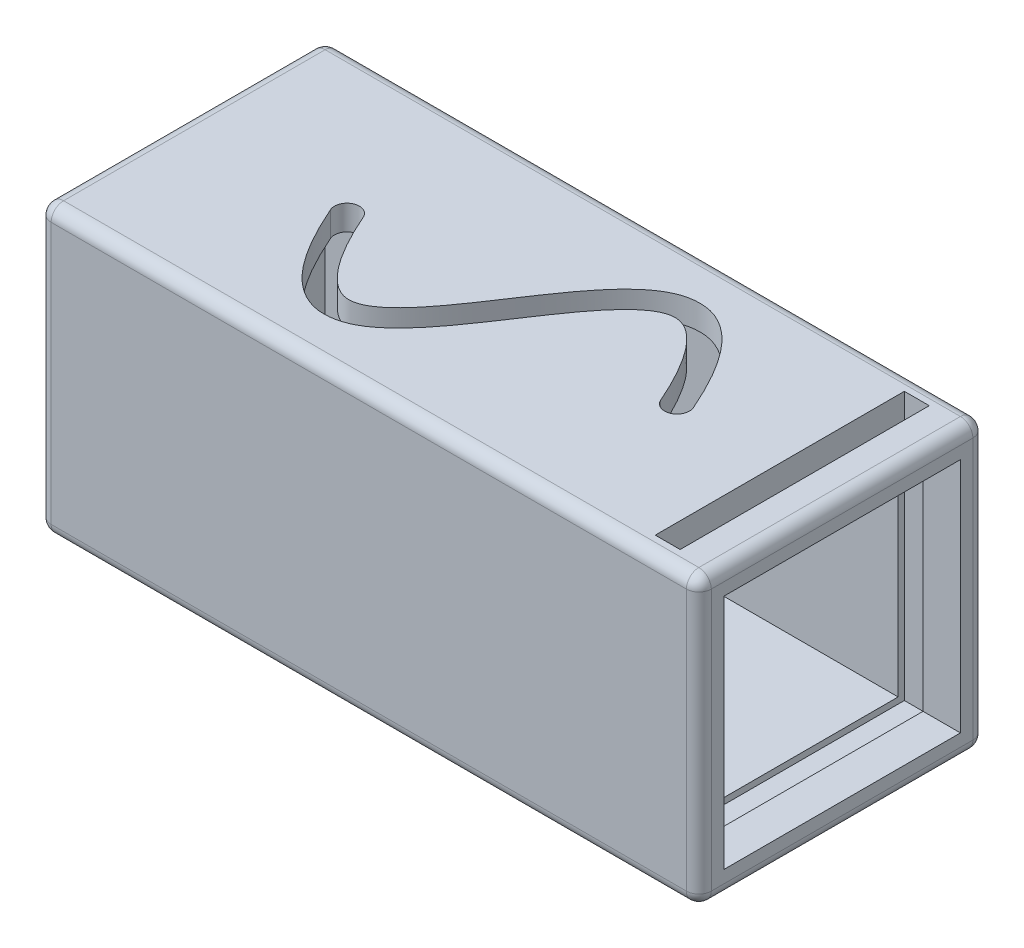
from build123d import *

# Parameters (mm, degrees)
SKETCH1_W           = 53
SKETCH1_H           = 23
BOSS_EXTRUDE1_DEPTH = 2
SKETCH3_W           = 53
SKETCH3_H           = 23
SKETCH3_W_2         = 49
SKETCH3_H_2         = 19
BOSS_EXTRUDE2_DEPTH = 19
SKETCH5_W           = 53
SKETCH5_H           = 23
BOSS_EXTRUDE3_DEPTH = 2
CUT_EXTRUDE1_REACH  = 25
CUT_EXTRUDE2_REACH  = 55
CUT_EXTRUDE3_REACH  = 55
SKETCH9_W           = 19
SKETCH9_H           = 19
SKETCH10_W          = 2
SKETCH10_H          = 20
CUT_EXTRUDE4_DEPTH  = 21.5
FILLET1_R           = 1


with BuildPart() as part:
    # Sketch1 → Boss-Extrude1 (new body)
    with BuildSketch(Plane(origin=(0, 0, 0), x_dir=(1, 0, 0), z_dir=(0, 1, 0))):
        with Locations((26.5, 11.5)):
            Rectangle(SKETCH1_W, SKETCH1_H)
        with BuildLine():
            ThreePointArc((14.167979799, 11.103372859), (12.853372859, 10.582020201), (12.332020201, 11.896627141))
            add(Edge.make_bspline(
                [(12.332020201, 11.896627141), (12.469480865, 12.214775093), (12.762832878, 12.862826424), (13.335933972, 14.00565416), (14.069559606, 15.249143301), (14.976946321, 16.440651864), (16.244519266, 17.664776994), (18.013213928, 18.520696074), (20.198395592, 18.347411342), (22.11067197, 17.353298864), (24.473450461, 15.381830316), (26.713246554, 12.781426707), (28.903370071, 10.24854759), (30.508326384, 8.567330823), (32.048368225, 7.290846303), (33.447040029, 6.607713215), (34.391956609, 6.552903154), (35.163585916, 6.806063587), (35.804481551, 7.206405018), (36.50793545, 7.876095679), (37.256247569, 8.85306811), (37.906431149, 9.951709918), (38.429850366, 10.994805159), (38.704188556, 11.600765219), (38.832020201, 11.896627141)],
                knots=[0, 0, 0, 0, 0.015625, 0.03125, 0.0625, 0.09375, 0.125, 0.1875, 0.25, 0.3125, 0.375, 0.5, 0.5625, 0.625, 0.6875, 0.75, 0.8125, 0.84375, 0.875, 0.90625, 0.9375, 0.96875, 0.984375, 1, 1, 1, 1], degree=3))
            ThreePointArc((38.832020201, 11.896627141), (40.146627141, 12.417979799), (40.667979799, 11.103372859))
            add(Edge.make_bspline(
                [(14.167979799, 11.103372859), (14.295811444, 11.399234781), (14.570149634, 12.005194841), (15.093568851, 13.048290082), (15.743752431, 14.14693189), (16.49206455, 15.123904321), (17.195518449, 15.793594982), (17.836414084, 16.193936413), (18.608043391, 16.447096846), (19.552959971, 16.392286785), (20.951631775, 15.709153697), (22.491673616, 14.432669177), (24.096629929, 12.75145241), (26.286753446, 10.218573293), (28.526549539, 7.618169684), (30.88932803, 5.646701136), (32.801604408, 4.652588658), (34.986786072, 4.479303926), (36.755480734, 5.335223006), (38.023053679, 6.559348136), (38.930440394, 7.750856699), (39.664066028, 8.99434584), (40.237167122, 10.137173576), (40.530519135, 10.785224907), (40.667979799, 11.103372859)],
                knots=[0, 0, 0, 0, 0.015625, 0.03125, 0.0625, 0.09375, 0.125, 0.15625, 0.1875, 0.25, 0.3125, 0.375, 0.4375, 0.5, 0.625, 0.6875, 0.75, 0.8125, 0.875, 0.90625, 0.9375, 0.96875, 0.984375, 1, 1, 1, 1], degree=3))
        make_face(mode=Mode.SUBTRACT)
    extrude(amount=BOSS_EXTRUDE1_DEPTH)

    # Sketch3 → Boss-Extrude2 (add)
    with BuildSketch(Plane(origin=(0, 2, 0), x_dir=(1, 0, 0), z_dir=(0, 1, 0))):
        with Locations((26.5, 11.5)):
            Rectangle(SKETCH3_W, SKETCH3_H)
        with Locations((26.5, 11.5)):
            Rectangle(SKETCH3_W_2, SKETCH3_H_2, mode=Mode.SUBTRACT)
    extrude(amount=BOSS_EXTRUDE2_DEPTH)

    # Sketch5 → Boss-Extrude3 (add)
    with BuildSketch(Plane(origin=(0, 21, 0), x_dir=(1, 0, 0), z_dir=(0, 1, 0))):
        with Locations((26.5, 11.5)):
            Rectangle(SKETCH5_W, SKETCH5_H)
    extrude(amount=BOSS_EXTRUDE3_DEPTH)

    # Sketch7 → Cut-Extrude1 (cut, up to next)
    with BuildSketch(Plane(origin=(0, 23, 0), x_dir=(1, 0, 0), z_dir=(0, 1, 0)), mode=Mode.PRIVATE) as cut_extrude1_sk1:
        with BuildLine():
            ThreePointArc((12.334246428, 11.098259542), (12.848259542, 12.415753572), (14.165753572, 11.901740458))
            add(Edge.make_bspline(
                [(14.165753572, 11.901740458), (14.319569541, 11.551122241), (14.647608492, 10.832183671), (15.265371347, 9.591848537), (16.019360121, 8.279562849), (16.869534053, 7.103102818), (17.654222781, 6.289831839), (18.34890312, 5.806641268), (18.938193167, 5.587801008), (19.463132193, 5.549931301), (20.195435511, 5.70020599), (21.280226269, 6.347578401), (22.712802701, 7.841295003), (24.17836504, 9.816346352), (26.159265484, 12.791351284), (28.18067633, 15.841945555), (30.383820425, 18.160165201), (32.247719208, 19.361531089), (34.538967294, 19.56728313), (36.355209033, 18.558624621), (37.689381474, 17.159152284), (38.675063468, 15.789280734), (39.49940357, 14.351448085), (40.159389491, 13.025812725), (40.503651701, 12.271246104), (40.665753572, 11.901740458)],
                knots=[0, 0, 0, 0, 0.015625, 0.03125, 0.0625, 0.09375, 0.125, 0.15625, 0.1875, 0.21875, 0.25, 0.3125, 0.375, 0.4375, 0.5, 0.625, 0.6875, 0.75, 0.8125, 0.875, 0.90625, 0.9375, 0.96875, 0.984375, 1, 1, 1, 1], degree=3))
            ThreePointArc((40.665753572, 11.901740458), (40.151740458, 10.584246428), (38.834246428, 11.098259542))
            add(Edge.make_bspline(
                [(12.334246428, 11.098259542), (12.496348299, 10.728753896), (12.840610509, 9.974187275), (13.50059643, 8.648551915), (14.324936532, 7.210719266), (15.310618526, 5.840847716), (16.644790967, 4.441375379), (18.461032706, 3.43271687), (20.752280792, 3.638468911), (22.616179575, 4.839834799), (24.81932367, 7.158054445), (26.840734516, 10.208648716), (28.82163496, 13.183653648), (30.287197299, 15.158704997), (31.719773731, 16.652421599), (32.804564489, 17.29979401), (33.536867807, 17.450068699), (34.061806833, 17.412198992), (34.65109688, 17.193358732), (35.345777219, 16.710168161), (36.130465947, 15.896897182), (36.980639879, 14.720437151), (37.734628653, 13.408151463), (38.352391508, 12.167816329), (38.680430459, 11.448877759), (38.834246428, 11.098259542)],
                knots=[0, 0, 0, 0, 0.015625, 0.03125, 0.0625, 0.09375, 0.125, 0.1875, 0.25, 0.3125, 0.375, 0.5, 0.5625, 0.625, 0.6875, 0.75, 0.78125, 0.8125, 0.84375, 0.875, 0.90625, 0.9375, 0.96875, 0.984375, 1, 1, 1, 1], degree=3))
        make_face()
    cut_extrude1_tool1 = extrude(cut_extrude1_sk1.sketch, amount=-CUT_EXTRUDE1_REACH, mode=Mode.PRIVATE) & part.part
    add(cut_extrude1_tool1.solids().sort_by_distance((26.5, 23, -11.500446))[0], mode=Mode.SUBTRACT)

    # Sketch8 → Cut-Extrude2 (cut, up to next)
    with BuildSketch(Plane.ZY, mode=Mode.PRIVATE) as cut_extrude2_sk1:
        Polygon((-4, 8), (-4, 15), (-5.4, 15), (-7.1, 15.5), (-8.5, 15.5), (-8.5, 7.5), (-7.1, 7.5), (-5.4, 8), align=None)
    cut_extrude2_tool1 = extrude(cut_extrude2_sk1.sketch, amount=-CUT_EXTRUDE2_REACH, mode=Mode.PRIVATE) & part.part
    add(cut_extrude2_tool1.solids().sort_by_distance((0, 11.5, -6.321432))[0], mode=Mode.SUBTRACT)

    # Sketch9 → Cut-Extrude3 (cut, up to next)
    with BuildSketch(Plane(origin=(53, 0, 0), x_dir=(0, 0, -1), z_dir=(1, 0, 0)), mode=Mode.PRIVATE) as cut_extrude3_sk1:
        with Locations((11.5, 11.5)):
            Rectangle(SKETCH9_W, SKETCH9_H)
    cut_extrude3_tool1 = extrude(cut_extrude3_sk1.sketch, amount=-CUT_EXTRUDE3_REACH, mode=Mode.PRIVATE) & part.part
    add(cut_extrude3_tool1.solids().sort_by_distance((53, 11.5, -11.5))[0], mode=Mode.SUBTRACT)

    # Sketch10 → Cut-Extrude4 (cut)
    with BuildSketch(Plane(origin=(0, 23, 0), x_dir=(1, 0, 0), z_dir=(0, 1, 0))):
        with Locations((49, 11.5)):
            Rectangle(SKETCH10_W, SKETCH10_H)
    extrude(amount=-CUT_EXTRUDE4_DEPTH, mode=Mode.SUBTRACT)

    # Fillet1
    fillet1_edges = [part.edges().sort_by_distance(p)[0] for p in [
        (26.5, 0, -23),
        (53, 0, -11.5),
        (26.5, 0, 0),
        (0, 23, -11.5),
        (26.5, 23, 0),
        (53, 23, -11.5),
        (26.5, 23, -23),
        (0, 0, -11.5),
        (0, 11.5, -23),
        (53, 11.5, -23),
        (53, 11.5, 0),
        (0, 11.5, 0),
    ]]
    fillet(fillet1_edges, radius=FILLET1_R)


solid = part.part
